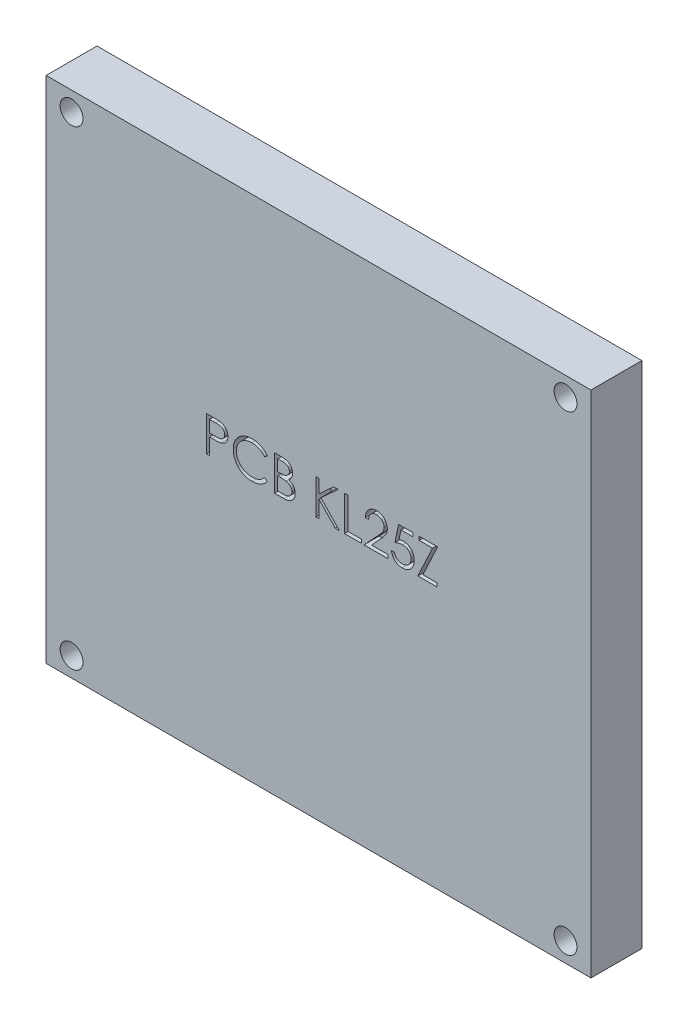
from build123d import *

# Parameters (mm, degrees)
CROQUIS1_W              = 107
CROQUIS1_H              = 100
SALIENTE_EXTRUIR1_DEPTH = 10
CORTAR_EXTRUIR1_DEPTH   = 3
CROQUIS4_R              = 2.25
CORTAR_EXTRUIR2_DEPTH   = 10


with BuildPart() as part:
    # Croquis1 → Saliente-Extruir1 (new body)
    with BuildSketch(Plane.XY):
        with Locations((9.288602269, -7.568965517)):
            Rectangle(CROQUIS1_W, CROQUIS1_H)
    extrude(amount=SALIENTE_EXTRUIR1_DEPTH)

    # Croquis2 → Cortar-Extruir1 (cut)
    with BuildSketch(Plane.XY.offset(10)):
        with BuildLine():
            Line((-12.748794183, 0.689506684), (-11.39969479, 0.689506684))
            add(Edge.make_bspline(
                [(-11.39969479, 0.689506684), (-11.306902878, 0.689404683), (-11.129109454, 0.689209245), (-10.874157601, 0.683283834), (-10.642605378, 0.675369467), (-10.43495207, 0.664398389), (-10.250558763, 0.651432947), (-10.090259832, 0.633248284), (-9.9527953, 0.614261203), (-9.870429171, 0.594957463), (-9.832865363, 0.58615382)],
                knots=[0, 0, 0, 0, 0.000278367, 0.000533364, 0.000765022, 0.000973397, 0.001157194, 0.001319416, 0.001457399, 0.001573089, 0.001573089, 0.001573089, 0.001573089], degree=3))
            add(Edge.make_bspline(
                [(-9.832865363, 0.58615382), (-9.785313549, 0.573138535), (-9.691330418, 0.547414654), (-9.555907059, 0.495892205), (-9.427062536, 0.434800949), (-9.304354795, 0.365176039), (-9.189291724, 0.284030246), (-9.080156613, 0.194652933), (-8.97791258, 0.094980552), (-8.883134582, -0.013868974), (-8.796093867, -0.130068338), (-8.721150884, -0.255352174), (-8.658398679, -0.387611628), (-8.604577511, -0.526754707), (-8.565841013, -0.673949855), (-8.536659785, -0.82817431), (-8.518137869, -0.98941154), (-8.516363906, -1.099595875), (-8.515460849, -1.155686458)],
                knots=[0, 0, 0, 0, 0.000147836, 0.000292188, 0.000433966, 0.00057532, 0.000714857, 0.000855835, 0.000998113, 0.001142656, 0.001288455, 0.00143309, 0.001579785, 0.001727203, 0.001879972, 0.002035648, 0.002197871, 0.002366082, 0.002366082, 0.002366082, 0.002366082], degree=3))
            add(Edge.make_bspline(
                [(-8.515460849, -1.155686458), (-8.51628915, -1.212248493), (-8.517909775, -1.322915935), (-8.537360688, -1.484817689), (-8.563560862, -1.639536811), (-8.603847331, -1.786730242), (-8.656611862, -1.925523858), (-8.718508742, -2.058038684), (-8.793164467, -2.182020277), (-8.87894734, -2.297918743), (-8.974374343, -2.405842868), (-9.079041725, -2.505010566), (-9.19252693, -2.594841354), (-9.314469295, -2.67553662), (-9.446057628, -2.745225094), (-9.585296195, -2.80764332), (-9.733395251, -2.860064655), (-9.835880121, -2.887640407), (-9.887986891, -2.901660851)],
                knots=[0, 0, 0, 0, 0.000169588, 0.000331811, 0.000488593, 0.000640033, 0.00078874, 0.000933598, 0.001078233, 0.001222104, 0.001365612, 0.001509879, 0.001654073, 0.001799311, 0.001947896, 0.002100268, 0.00225674, 0.002418582, 0.002418582, 0.002418582, 0.002418582], degree=3))
            add(Edge.make_bspline(
                [(-9.887986891, -2.901660851), (-9.931084544, -2.910825829), (-10.025535556, -2.930911412), (-10.181088692, -2.953334462), (-10.362198254, -2.972473484), (-10.568617045, -2.986823696), (-10.800159781, -2.999108647), (-11.056951716, -3.008873317), (-11.339496932, -3.01423878), (-11.536577675, -3.014515505), (-11.639473436, -3.014659982)],
                knots=[0, 0, 0, 0, 0.000132155, 0.000289626, 0.000471177, 0.000678438, 0.00091028, 0.001166777, 0.001449328, 0.001758012, 0.001758012, 0.001758012, 0.001758012], degree=3))
            Line((-11.639473436, -3.014659982), (-12.131433072, -3.014659982))
            Line((-12.131433072, -3.014659982), (-12.131433072, -6.189659982))
            Line((-12.131433072, -6.189659982), (-12.748794183, -6.189659982))
            Line((-12.748794183, -6.189659982), (-12.748794183, 0.689506684))
        make_face()
        with BuildLine():
            Line((-12.131433072, -0.016048871), (-12.131433072, -2.309104427))
            Line((-12.131433072, -2.309104427), (-10.92702769, -2.324262847))
            add(Edge.make_bspline(
                [(-10.92702769, -2.324262847), (-10.868220788, -2.32429324), (-10.754695276, -2.324351914), (-10.590703366, -2.316519052), (-10.438557255, -2.307476815), (-10.298724286, -2.294237518), (-10.171141424, -2.275523713), (-10.055595936, -2.256632071), (-9.952983764, -2.229301412), (-9.832894738, -2.192501665), (-9.69907854, -2.129738869), (-9.553500537, -2.038639264), (-9.430126444, -1.922517539), (-9.323365125, -1.791955218), (-9.238641548, -1.646708238), (-9.176618996, -1.491300126), (-9.140176793, -1.327324674), (-9.135290239, -1.215119296), (-9.13282196, -1.158442535)],
                knots=[0, 0, 0, 0, 0.000176394, 0.000340526, 0.000492416, 0.00063365, 0.000761689, 0.000879275, 0.000984558, 0.001080001, 0.001255748, 0.00142623, 0.001592996, 0.001761511, 0.001930735, 0.002095277, 0.002261786, 0.002431737, 0.002431737, 0.002431737, 0.002431737], degree=3))
            add(Edge.make_bspline(
                [(-9.13282196, -1.158442535), (-9.135303662, -1.103136956), (-9.140236978, -0.993196312), (-9.176904633, -0.83206901), (-9.238520963, -0.678298595), (-9.323933864, -0.534871734), (-9.4275953, -0.404779215), (-9.548077699, -0.291769981), (-9.685097454, -0.200922325), (-9.812555108, -0.14228572), (-9.925768868, -0.10648403), (-10.024105494, -0.081434349), (-10.13513657, -0.061434438), (-10.258898241, -0.045239891), (-10.394431256, -0.031376481), (-10.542900016, -0.021969757), (-10.703742093, -0.016463561), (-10.815401917, -0.016190448), (-10.8732842, -0.016048871)],
                knots=[0, 0, 0, 0, 0.000165829, 0.000329648, 0.000492909, 0.000660945, 0.000828596, 0.000990455, 0.001154419, 0.001319674, 0.001409448, 0.001510384, 0.001623903, 0.001747658, 0.001884778, 0.002032543, 0.002193868, 0.002367506, 0.002367506, 0.002367506, 0.002367506], degree=3))
            Line((-10.8732842, -0.016048871), (-12.131433072, -0.016048871))
        make_face(mode=Mode.SUBTRACT)
        with BuildLine():
            Line((-0.754349738, -0.572776302), (-1.29454071, -0.98618776))
            add(Edge.make_bspline(
                [(-1.29454071, -0.98618776), (-1.333075617, -0.940262503), (-1.409625897, -0.84903116), (-1.532781067, -0.720922317), (-1.661129892, -0.6009), (-1.794623307, -0.488392448), (-1.935664148, -0.38733402), (-2.080835789, -0.292458316), (-2.232566709, -0.207416607), (-2.442384702, -0.104301857), (-2.716859223, 0.003300407), (-3.062379793, 0.093522115), (-3.423066488, 0.15095564), (-3.669139389, 0.157176061), (-3.794301995, 0.160340018)],
                knots=[0, 0, 0, 0, 0.000179812, 0.000357199, 0.000532692, 0.000706838, 0.000880493, 0.00105288, 0.001226884, 0.001401911, 0.001754034, 0.002109015, 0.00247152, 0.002846774, 0.002846774, 0.002846774, 0.002846774], degree=3))
            add(Edge.make_bspline(
                [(-3.794301995, 0.160340018), (-3.863257385, 0.159546039), (-4.000528193, 0.15796545), (-4.2042468, 0.137113467), (-4.40416138, 0.107805839), (-4.600141893, 0.064319043), (-4.791938874, 0.009339526), (-4.980806203, -0.056357329), (-5.164009417, -0.137639282), (-5.344082883, -0.227477779), (-5.516610832, -0.328950292), (-5.679853551, -0.439632844), (-5.833215664, -0.558286866), (-5.976818489, -0.685357076), (-6.11080883, -0.820271215), (-6.234215795, -0.964467082), (-6.346612357, -1.117483675), (-6.450226414, -1.277303242), (-6.543021918, -1.443460259), (-6.620716955, -1.616569713), (-6.689518689, -1.793667182), (-6.743960891, -1.97675357), (-6.787053007, -2.164540602), (-6.816786068, -2.357532258), (-6.837400909, -2.555325359), (-6.838973638, -2.689389139), (-6.839766405, -2.75696684)],
                knots=[0, 0, 0, 0, 0.000206779, 0.000411639, 0.000613742, 0.000812686, 0.001013331, 0.001212075, 0.001412023, 0.001614163, 0.001815526, 0.002011983, 0.002205483, 0.002396827, 0.002586841, 0.002775472, 0.002965646, 0.003156, 0.003346598, 0.003535917, 0.003724788, 0.003916177, 0.004108397, 0.004302329, 0.004501702, 0.004704349, 0.004704349, 0.004704349, 0.004704349], degree=3))
            add(Edge.make_bspline(
                [(-6.839766405, -2.75696684), (-6.83728633, -2.858643518), (-6.832417031, -3.058272187), (-6.789081555, -3.35067728), (-6.723228096, -3.630798271), (-6.624530575, -3.896884128), (-6.502830156, -4.152215913), (-6.349050096, -4.392473469), (-6.17094545, -4.621287454), (-5.965996561, -4.8332502), (-5.741134654, -5.026876582), (-5.499876556, -5.197382784), (-5.242823152, -5.339515964), (-4.972812657, -5.457790354), (-4.687767283, -5.548706851), (-4.388199617, -5.612710861), (-4.074761208, -5.654461861), (-3.860584447, -5.658459026), (-3.751582811, -5.660493316)],
                knots=[0, 0, 0, 0, 0.000304858, 0.000598548, 0.000884985, 0.001166604, 0.001448267, 0.001731942, 0.002020561, 0.002316843, 0.002614885, 0.00290965, 0.003201436, 0.003494573, 0.003792663, 0.004097284, 0.004412641, 0.004739472, 0.004739472, 0.004739472, 0.004739472], degree=3))
            add(Edge.make_bspline(
                [(-3.751582811, -5.660493316), (-3.631486931, -5.657174059), (-3.395109509, -5.650640969), (-3.048462352, -5.595294635), (-2.716619675, -5.505555085), (-2.399563627, -5.37996524), (-2.09818803, -5.216702394), (-1.812021261, -5.018783114), (-1.54082177, -4.784324736), (-1.37774369, -4.605303016), (-1.29454071, -4.513965538)],
                knots=[0, 0, 0, 0, 0.000360114, 0.00070879, 0.001050104, 0.001389678, 0.001729409, 0.002076111, 0.002431703, 0.002802111, 0.002802111, 0.002802111, 0.002802111], degree=3))
            Line((-1.29454071, -4.513965538), (-0.754349738, -4.923242882))
            add(Edge.make_bspline(
                [(-0.754349738, -4.923242882), (-0.797822357, -4.97933453), (-0.884559362, -5.091249149), (-1.025008393, -5.249021283), (-1.172964129, -5.397422668), (-1.32952553, -5.535256837), (-1.49289157, -5.665281864), (-1.665995603, -5.783803678), (-1.846561999, -5.892476595), (-2.033978957, -5.991982609), (-2.22804735, -6.080266389), (-2.428534638, -6.155846354), (-2.634576638, -6.220952536), (-2.84618277, -6.274515568), (-3.063791954, -6.316323377), (-3.286618921, -6.34427181), (-3.515144593, -6.363419311), (-3.669319338, -6.365164488), (-3.747448697, -6.366048871)],
                knots=[0, 0, 0, 0, 0.000212848, 0.000424676, 0.000633202, 0.00084114, 0.001050116, 0.001259201, 0.001470009, 0.001682066, 0.001895449, 0.002109156, 0.002324456, 0.002543374, 0.00276364, 0.00298875, 0.003216831, 0.003451162, 0.003451162, 0.003451162, 0.003451162], degree=3))
            add(Edge.make_bspline(
                [(-3.747448697, -6.366048871), (-3.821436428, -6.365533931), (-3.967738004, -6.364515701), (-4.183741384, -6.348021096), (-4.394026858, -6.32551691), (-4.597993414, -6.291631843), (-4.79675411, -6.251645527), (-4.988507116, -6.198044522), (-5.175139321, -6.138000862), (-5.355900905, -6.067430466), (-5.530945625, -5.987796873), (-5.699708902, -5.897794655), (-5.862113118, -5.798180656), (-6.019754963, -5.69115063), (-6.17030569, -5.573266671), (-6.315069941, -5.446165941), (-6.454859474, -5.310276827), (-6.541345704, -5.212288299), (-6.584829339, -5.163021528)],
                knots=[0, 0, 0, 0, 0.000221903, 0.000438785, 0.000649553, 0.000856167, 0.001058865, 0.001257441, 0.001453108, 0.001646829, 0.001839227, 0.00202972, 0.002220209, 0.002410558, 0.002601036, 0.002793415, 0.002988309, 0.003185382, 0.003185382, 0.003185382, 0.003185382], degree=3))
            add(Edge.make_bspline(
                [(-6.584829339, -5.163021528), (-6.654477253, -5.077442357), (-6.792932229, -4.907317204), (-6.970072114, -4.631588448), (-7.121703797, -4.343708671), (-7.244302184, -4.042165454), (-7.340144175, -3.727635434), (-7.40654031, -3.39996006), (-7.449685666, -3.059445355), (-7.454619579, -2.827839952), (-7.457127516, -2.710113541)],
                knots=[0, 0, 0, 0, 0.000330801, 0.000657608, 0.000981212, 0.001305696, 0.001632642, 0.001966145, 0.002307654, 0.002660701, 0.002660701, 0.002660701, 0.002660701], degree=3))
            add(Edge.make_bspline(
                [(-7.457127516, -2.710113541), (-7.45407082, -2.586376096), (-7.448056962, -2.342930398), (-7.396962845, -1.985658021), (-7.314768996, -1.643367593), (-7.198025826, -1.31669809), (-7.050014951, -1.003931313), (-6.867173357, -0.707456517), (-6.6516252, -0.425377664), (-6.405060992, -0.161974861), (-6.13467567, 0.078873319), (-5.845124049, 0.290763845), (-5.536972865, 0.467101487), (-5.213616945, 0.614504659), (-4.872634968, 0.727803478), (-4.514754442, 0.807116706), (-4.140647836, 0.8564838), (-3.885406331, 0.862724596), (-3.755716926, 0.865895573)],
                knots=[0, 0, 0, 0, 0.000371061, 0.000730039, 0.001080313, 0.001425516, 0.00176885, 0.002116512, 0.002468476, 0.002832155, 0.003197218, 0.003553342, 0.003906475, 0.004260478, 0.004617812, 0.004982219, 0.005358769, 0.005747728, 0.005747728, 0.005747728, 0.005747728], degree=3))
            add(Edge.make_bspline(
                [(-3.755716926, 0.865895573), (-3.676676339, 0.864947942), (-3.520223456, 0.863072202), (-3.288783422, 0.844781201), (-3.063456658, 0.814289577), (-2.84408793, 0.772786445), (-2.629610026, 0.721276578), (-2.421662172, 0.654174635), (-2.219024157, 0.577449262), (-2.022973984, 0.489084468), (-1.834452289, 0.389893289), (-1.653517786, 0.2809752), (-1.481607689, 0.16246523), (-1.317512345, 0.035371299), (-1.163976792, -0.102995394), (-1.016641791, -0.248829002), (-0.880510791, -0.406330125), (-0.796480404, -0.51719268), (-0.754349738, -0.572776302)],
                knots=[0, 0, 0, 0, 0.000237087, 0.000469289, 0.000695946, 0.00091892, 0.001138841, 0.001357185, 0.001573958, 0.001788596, 0.002001872, 0.00221268, 0.002421766, 0.002627956, 0.002834864, 0.003041441, 0.003249506, 0.003458719, 0.003458719, 0.003458719, 0.003458719], degree=3))
        make_face()
        with BuildLine():
            Line((0.656761373, 0.689506684), (1.998970574, 0.689506684))
            add(Edge.make_bspline(
                [(1.998970574, 0.689506684), (2.064673452, 0.689161251), (2.192021982, 0.688491715), (2.377208051, 0.678107847), (2.550658987, 0.663949205), (2.712425092, 0.64148363), (2.862431616, 0.614376221), (3.001130627, 0.581549199), (3.128081072, 0.542187367), (3.27964432, 0.479594259), (3.452450285, 0.386581698), (3.63956046, 0.249138769), (3.799558554, 0.081026749), (3.937508089, -0.108607613), (4.047183861, -0.317214946), (4.126528754, -0.539823184), (4.176762149, -0.773561037), (4.181928274, -0.934028759), (4.184539151, -1.015126562)],
                knots=[0, 0, 0, 0, 0.000197079, 0.000381988, 0.000556281, 0.000719012, 0.000871726, 0.001013443, 0.001146372, 0.001269973, 0.001504891, 0.001733372, 0.001963368, 0.002198217, 0.002434919, 0.002667681, 0.002905512, 0.003148519, 0.003148519, 0.003148519, 0.003148519], degree=3))
            add(Edge.make_bspline(
                [(4.184539151, -1.015126562), (4.182390456, -1.09109724), (4.178168068, -1.240386787), (4.137791764, -1.458739613), (4.074580735, -1.666591116), (3.986713633, -1.863182733), (3.872515542, -2.044072608), (3.737176157, -2.210719961), (3.573890679, -2.356069003), (3.451553073, -2.437327494), (3.389411112, -2.478603125)],
                knots=[0, 0, 0, 0, 0.000227714, 0.00044748, 0.000663687, 0.000878325, 0.001091298, 0.001303735, 0.001520372, 0.001744014, 0.001744014, 0.001744014, 0.001744014], degree=3))
            add(Edge.make_bspline(
                [(3.389411112, -2.478603125), (3.467559286, -2.508606117), (3.617076101, -2.566009273), (3.822833966, -2.667497548), (4.000109787, -2.777882839), (4.150266558, -2.89842913), (4.278686163, -3.028364423), (4.390822361, -3.16959394), (4.486504443, -3.323959998), (4.568490201, -3.489853137), (4.632464006, -3.665579422), (4.680374266, -3.849490555), (4.707826955, -4.040927061), (4.711733616, -4.171209396), (4.713705817, -4.236979861)],
                knots=[0, 0, 0, 0, 0.000251034, 0.00048029, 0.000687129, 0.000876302, 0.001056572, 0.001234125, 0.001416131, 0.001600402, 0.001788306, 0.001976144, 0.002169664, 0.002366959, 0.002366959, 0.002366959, 0.002366959], degree=3))
            add(Edge.make_bspline(
                [(4.713705817, -4.236979861), (4.71178585, -4.304134035), (4.70800826, -4.436261753), (4.680137863, -4.630362618), (4.632948535, -4.815854329), (4.567947984, -4.993936658), (4.483113482, -5.164265089), (4.379871019, -5.327032588), (4.256770172, -5.480603754), (4.119063271, -5.626685066), (3.963275411, -5.758033491), (3.795196231, -5.875010195), (3.612709, -5.971212515), (3.418810855, -6.052025076), (3.211326705, -6.113755177), (2.991188247, -6.156941748), (2.758585339, -6.186040696), (2.598969507, -6.188433083), (2.517112935, -6.189659982)],
                knots=[0, 0, 0, 0, 0.000201425, 0.000396309, 0.000586817, 0.000774721, 0.000963919, 0.001156594, 0.001351794, 0.001553558, 0.001757884, 0.001962001, 0.002166681, 0.002375507, 0.002591314, 0.002814815, 0.003047961, 0.003293391, 0.003293391, 0.003293391, 0.003293391], degree=3))
            Line((2.517112935, -6.189659982), (0.656761373, -6.189659982))
            Line((0.656761373, -6.189659982), (0.656761373, 0.689506684))
        make_face()
        with BuildLine():
            Line((1.274122484, -0.016048871), (1.274122484, -2.220909982))
            Line((1.274122484, -2.220909982), (1.688911981, -2.220909982))
            add(Edge.make_bspline(
                [(1.688911981, -2.220909982), (1.749544553, -2.220123943), (1.86669904, -2.218605155), (2.036358742, -2.21425454), (2.193842557, -2.202072434), (2.338878648, -2.189893828), (2.471238618, -2.170092466), (2.590629232, -2.146522234), (2.698924212, -2.121594286), (2.823809676, -2.079199973), (2.96546734, -2.016545161), (3.116480977, -1.919309445), (3.249611464, -1.803495032), (3.362031175, -1.669860416), (3.454038006, -1.52271271), (3.517942939, -1.364399734), (3.561276351, -1.19886707), (3.565190658, -1.085226671), (3.56717804, -1.027528906)],
                knots=[0, 0, 0, 0, 0.000181922, 0.00035151, 0.000508993, 0.000655714, 0.000788041, 0.000910198, 0.001020828, 0.001121056, 0.001305471, 0.001483984, 0.001657825, 0.001832857, 0.002006101, 0.002176025, 0.002343472, 0.002516173, 0.002516173, 0.002516173, 0.002516173], degree=3))
            add(Edge.make_bspline(
                [(3.56717804, -1.027528906), (3.566143845, -0.989348015), (3.564115159, -0.914452027), (3.547500394, -0.805271094), (3.519261269, -0.702587242), (3.482989795, -0.604993271), (3.432302741, -0.515540813), (3.372624077, -0.431136984), (3.300519226, -0.354656142), (3.218446222, -0.283172759), (3.124086417, -0.219796907), (3.017496104, -0.164290359), (2.897233182, -0.119593904), (2.765324463, -0.080449181), (2.619739505, -0.052955522), (2.462158329, -0.030051066), (2.291290208, -0.018390403), (2.173076441, -0.016846791), (2.111969706, -0.016048871)],
                knots=[0, 0, 0, 0, 0.00011451, 0.000224624, 0.000330257, 0.000433647, 0.00053604, 0.000637763, 0.000743073, 0.000850542, 0.000963675, 0.001083247, 0.001210184, 0.001347988, 0.001495547, 0.001654184, 0.00182551, 0.002008835, 0.002008835, 0.002008835, 0.002008835], degree=3))
            Line((2.111969706, -0.016048871), (1.274122484, -0.016048871))
        make_face(mode=Mode.SUBTRACT)
        with BuildLine():
            Line((1.274122484, -2.926465538), (1.274122484, -5.484104427))
            Line((1.274122484, -5.484104427), (2.153310852, -5.484104427))
            add(Edge.make_bspline(
                [(2.153310852, -5.484104427), (2.216243289, -5.483350181), (2.337537263, -5.48189647), (2.51266361, -5.477150721), (2.674978734, -5.466355783), (2.823741963, -5.449362572), (2.96055965, -5.430929453), (3.083790493, -5.406142281), (3.194433424, -5.377743193), (3.322728522, -5.333845909), (3.467197917, -5.265650822), (3.622884969, -5.162828455), (3.761306024, -5.040333478), (3.878851837, -4.898561883), (3.975185699, -4.744406978), (4.045265647, -4.580986772), (4.088488153, -4.411001527), (4.093720583, -4.295103857), (4.096344706, -4.236979861)],
                knots=[0, 0, 0, 0, 0.000188811, 0.000363909, 0.000525516, 0.00067663, 0.000813048, 0.000939528, 0.001053506, 0.001155481, 0.001345959, 0.001530945, 0.001713477, 0.001898386, 0.002081561, 0.002256897, 0.002430026, 0.002604205, 0.002604205, 0.002604205, 0.002604205], degree=3))
            add(Edge.make_bspline(
                [(4.096344706, -4.236979861), (4.09580203, -4.20063164), (4.09472543, -4.1285215), (4.078489388, -4.022551241), (4.054876413, -3.91990253), (4.02434975, -3.820296638), (3.979891726, -3.725534395), (3.92799029, -3.633741626), (3.867136392, -3.544796989), (3.772313633, -3.432347667), (3.634392268, -3.302789348), (3.438420975, -3.175942424), (3.215590423, -3.073643698), (3.053974243, -3.030207704), (2.970487501, -3.007769791)],
                knots=[0, 0, 0, 0, 0.000108943, 0.00021613, 0.000320761, 0.000424919, 0.000527904, 0.000634048, 0.000741075, 0.000850644, 0.001074896, 0.00130575, 0.0015481, 0.001807069, 0.001807069, 0.001807069, 0.001807069], degree=3))
            add(Edge.make_bspline(
                [(2.970487501, -3.007769791), (2.937017219, -3.000978906), (2.864446743, -2.986254866), (2.746110177, -2.970712464), (2.611011463, -2.956865566), (2.458838641, -2.94662316), (2.289399182, -2.936036037), (2.102331215, -2.931918716), (1.898398683, -2.927006479), (1.756899389, -2.926650464), (1.683399828, -2.926465538)],
                knots=[0, 0, 0, 0, 0.00010243, 0.000222089, 0.000357838, 0.000509823, 0.000679596, 0.00086709, 0.001071082, 0.001291572, 0.001291572, 0.001291572, 0.001291572], degree=3))
            Line((1.683399828, -2.926465538), (1.274122484, -2.926465538))
        make_face(mode=Mode.SUBTRACT)
        Polygon((8.770650262, 0.689506684), (9.388011373, 0.689506684), (9.388011373, -1.930143923), (12.255708856, 0.689506684), (13.136275262, 0.689506684), (9.755947571, -2.397298871), (13.400858595, -6.189659982), (12.578169793, -6.189659982), (9.388011373, -2.869965972), (9.388011373, -6.189659982), (8.770650262, -6.189659982), align=None)
        Polygon((14.415094706, 0.689506684), (15.032455817, 0.689506684), (15.032455817, -5.484104427), (17.678289151, -5.484104427), (17.678289151, -6.189659982), (14.415094706, -6.189659982), align=None)
        with BuildLine():
            Line((19.089400262, -1.427159982), (18.472039151, -1.427159982))
            add(Edge.make_bspline(
                [(18.472039151, -1.427159982), (18.476062781, -1.345256845), (18.483965084, -1.184401262), (18.520971639, -0.949872965), (18.573923291, -0.725700974), (18.648791137, -0.513685226), (18.7417705, -0.311951094), (18.853272018, -0.121299873), (18.985339931, 0.057541142), (19.135122453, 0.222914035), (19.297802242, 0.374624368), (19.47333094, 0.505633661), (19.657781106, 0.616324703), (19.850593139, 0.708861763), (20.053942414, 0.778321388), (20.265983602, 0.829859397), (20.48764831, 0.860867429), (20.638675543, 0.864200455), (20.715485331, 0.865895573)],
                knots=[0, 0, 0, 0, 0.000245848, 0.000482838, 0.000711119, 0.000936005, 0.001156121, 0.001376628, 0.001597398, 0.00182182, 0.002045134, 0.002263691, 0.002477572, 0.002689615, 0.002904032, 0.003120949, 0.00334351, 0.003573844, 0.003573844, 0.003573844, 0.003573844], degree=3))
            add(Edge.make_bspline(
                [(20.715485331, 0.865895573), (20.790916522, 0.864129678), (20.939136118, 0.860659758), (21.155460386, 0.830861116), (21.361397664, 0.784189721), (21.556545405, 0.718709064), (21.739346611, 0.630686338), (21.911174523, 0.524948557), (22.074074783, 0.402656959), (22.22071264, 0.258678333), (22.355363639, 0.104973409), (22.471527714, -0.059120078), (22.571006682, -0.228601686), (22.653925562, -0.404763782), (22.714965664, -0.589265054), (22.76130807, -0.779419377), (22.787502785, -0.977195048), (22.791523016, -1.111056861), (22.793566928, -1.179113107)],
                knots=[0, 0, 0, 0, 0.000226204, 0.000444483, 0.000653745, 0.000858999, 0.001060555, 0.001260974, 0.00146355, 0.001670164, 0.001876285, 0.002075887, 0.00227229, 0.002465264, 0.00265875, 0.002854281, 0.003051706, 0.003255884, 0.003255884, 0.003255884, 0.003255884], degree=3))
            add(Edge.make_bspline(
                [(22.793566928, -1.179113107), (22.790238861, -1.274925816), (22.783641128, -1.464869855), (22.727203704, -1.743996686), (22.639058955, -2.014433275), (22.532928435, -2.232084806), (22.425864144, -2.407471113), (22.329383816, -2.551872104), (22.216438098, -2.707352018), (22.085383098, -2.873390213), (21.938929822, -3.051287242), (21.775751737, -3.240935638), (21.594685226, -3.440375985), (21.467600482, -3.576594495), (21.401748352, -3.647179514)],
                knots=[0, 0, 0, 0, 0.000287191, 0.000569343, 0.000850854, 0.001138679, 0.001293241, 0.001467141, 0.001659539, 0.001869599, 0.002101621, 0.002350787, 0.002620073, 0.002909674, 0.002909674, 0.002909674, 0.002909674], degree=3))
            Line((21.401748352, -3.647179514), (19.680578647, -5.484104427))
            Line((19.680578647, -5.484104427), (22.881761373, -5.484104427))
            Line((22.881761373, -5.484104427), (22.881761373, -6.189659982))
            Line((22.881761373, -6.189659982), (18.207455817, -6.189659982))
            Line((18.207455817, -6.189659982), (20.875337762, -3.342633073))
            add(Edge.make_bspline(
                [(20.875337762, -3.342633073), (20.940292596, -3.274827473), (21.06505754, -3.144586792), (21.241523057, -2.954440807), (21.400017069, -2.778040221), (21.54156554, -2.615718327), (21.663097822, -2.465100805), (21.770947888, -2.331065739), (21.85736121, -2.207723361), (21.951144684, -2.064753416), (22.041977164, -1.890194921), (22.120030855, -1.676874539), (22.167624563, -1.457277284), (22.173333948, -1.308879828), (22.176205817, -1.234234635)],
                knots=[0, 0, 0, 0, 0.00028169, 0.000541069, 0.000778192, 0.00099313, 0.001187047, 0.001358794, 0.001509057, 0.001638637, 0.001871619, 0.002097432, 0.002318512, 0.002542268, 0.002542268, 0.002542268, 0.002542268], degree=3))
            add(Edge.make_bspline(
                [(22.176205817, -1.234234635), (22.174956281, -1.187296315), (22.172493685, -1.0947899), (22.150760044, -0.959160724), (22.117915942, -0.828329167), (22.070852107, -0.701892798), (22.008729812, -0.581122832), (21.9331113, -0.46587226), (21.845863687, -0.354451449), (21.74493399, -0.249979907), (21.634058491, -0.154298157), (21.516927412, -0.069538794), (21.393003934, 0.00129522), (21.262810551, 0.059362261), (21.126710229, 0.104912921), (20.984439736, 0.136475676), (20.836392175, 0.156292558), (20.735300864, 0.158973806), (20.683790453, 0.160340018)],
                knots=[0, 0, 0, 0, 0.000140729, 0.000277349, 0.00041104, 0.000544909, 0.000681112, 0.000817565, 0.000957888, 0.001105055, 0.001252582, 0.001396757, 0.001538112, 0.001679989, 0.001823795, 0.001967884, 0.002116591, 0.002271085, 0.002271085, 0.002271085, 0.002271085], degree=3))
            add(Edge.make_bspline(
                [(20.683790453, 0.160340018), (20.629993733, 0.158934639), (20.524345857, 0.156174707), (20.369232377, 0.136868494), (20.221259974, 0.103561849), (20.080056424, 0.058008647), (19.945382809, 0.000108571), (19.817894075, -0.07200818), (19.69787642, -0.158063593), (19.58510423, -0.255630925), (19.481201337, -0.364258079), (19.389911109, -0.485350995), (19.310144195, -0.616698688), (19.24054819, -0.757946752), (19.184029566, -0.91037686), (19.140841862, -1.073447908), (19.106668429, -1.246451838), (19.09525192, -1.365923475), (19.089400262, -1.427159982)],
                knots=[0, 0, 0, 0, 0.000161378, 0.000316919, 0.000468033, 0.000615766, 0.000761428, 0.000907057, 0.001054275, 0.001203746, 0.001353858, 0.001504342, 0.001657725, 0.001814265, 0.001976036, 0.002144518, 0.002319919, 0.00250436, 0.00250436, 0.00250436, 0.00250436], degree=3))
        make_face()
        with BuildLine():
            Line((27.820650262, 0.689506684), (27.820650262, -0.016048871))
            Line((27.820650262, -0.016048871), (25.480741408, -0.016048871))
            Line((25.480741408, -0.016048871), (25.110049133, -1.825413021))
            add(Edge.make_bspline(
                [(25.110049133, -1.825413021), (25.182881572, -1.805305665), (25.323982903, -1.766350844), (25.532244487, -1.723099026), (25.729956068, -1.697026111), (25.858253254, -1.693466024), (25.920335592, -1.691743316)],
                knots=[0, 0, 0, 0, 0.000226623, 0.000439047, 0.000637661, 0.00082388, 0.00082388, 0.00082388, 0.00082388], degree=3))
            add(Edge.make_bspline(
                [(25.920335592, -1.691743316), (25.997153751, -1.693405982), (26.148197447, -1.6966752), (26.36919352, -1.72806749), (26.580153766, -1.777479393), (26.780636996, -1.846507943), (26.971014102, -1.934776954), (27.149533512, -2.045040051), (27.318874838, -2.173844253), (27.476000103, -2.32193308), (27.618544904, -2.484913544), (27.743875439, -2.660151216), (27.85033072, -2.845943086), (27.935948347, -3.044064282), (28.004316128, -3.252324475), (28.049820822, -3.472914944), (28.080121997, -3.703756428), (28.083507306, -3.861593148), (28.085233595, -3.942079687)],
                knots=[0, 0, 0, 0, 0.000230334, 0.000452895, 0.000668152, 0.000879513, 0.001087889, 0.001296342, 0.001507739, 0.001725142, 0.001942929, 0.002156307, 0.002370475, 0.002583996, 0.002802761, 0.003026823, 0.003258767, 0.003500117, 0.003500117, 0.003500117, 0.003500117], degree=3))
            add(Edge.make_bspline(
                [(28.085233595, -3.942079687), (28.083926405, -3.998139432), (28.081329692, -4.109501323), (28.068124468, -4.274884746), (28.042699626, -4.436766934), (28.008563778, -4.595169361), (27.964257192, -4.749792139), (27.910621206, -4.901077845), (27.844982109, -5.048084863), (27.772984013, -5.192204181), (27.691915043, -5.330177676), (27.601938477, -5.459209196), (27.506877255, -5.581234373), (27.404591151, -5.694944508), (27.294129433, -5.799592392), (27.176829879, -5.895799073), (27.053628488, -5.985191545), (26.922619196, -6.064141176), (26.786721292, -6.136790987), (26.64397226, -6.196391177), (26.497621526, -6.249676275), (26.345562705, -6.292149287), (26.188140224, -6.32542982), (26.025094588, -6.348033976), (25.857280914, -6.364497665), (25.743528954, -6.365528276), (25.686069099, -6.366048871)],
                knots=[0, 0, 0, 0, 0.000168211, 0.000334149, 0.000497276, 0.000659452, 0.000819968, 0.0009795, 0.001140547, 0.00130263, 0.00146263, 0.001620119, 0.001774219, 0.001926429, 0.002078488, 0.002230229, 0.002381292, 0.002534676, 0.002688776, 0.002843123, 0.002998297, 0.003155786, 0.003316326, 0.003480613, 0.003649416, 0.00382172, 0.00382172, 0.00382172, 0.00382172], degree=3))
            add(Edge.make_bspline(
                [(25.686069099, -6.366048871), (25.617524727, -6.364691046), (25.482671773, -6.362019684), (25.285100991, -6.33407359), (25.095010737, -6.294048797), (24.913931216, -6.233833938), (24.740239602, -6.158384625), (24.576274236, -6.063027245), (24.417845502, -5.954967125), (24.271393868, -5.827446336), (24.135469174, -5.688063252), (24.013793405, -5.53680484), (23.905429672, -5.376167568), (23.812113291, -5.205371315), (23.732515394, -5.024864869), (23.669983792, -4.833971923), (23.619513597, -4.633689892), (23.598161803, -4.495804837), (23.587316928, -4.425771094)],
                knots=[0, 0, 0, 0, 0.000205494, 0.000404285, 0.00059755, 0.000787549, 0.000975741, 0.001164613, 0.001355743, 0.001550203, 0.001746083, 0.001939132, 0.002131762, 0.002326646, 0.002522254, 0.00272271, 0.002928592, 0.003141096, 0.003141096, 0.003141096, 0.003141096], degree=3))
            Line((23.587316928, -4.425771094), (24.20467804, -4.425771094))
            add(Edge.make_bspline(
                [(24.20467804, -4.425771094), (24.219868335, -4.491371716), (24.249064927, -4.617459755), (24.313150749, -4.794610761), (24.391506178, -4.952476283), (24.484678297, -5.093144594), (24.595826035, -5.215807993), (24.722657091, -5.325122004), (24.864854819, -5.423740026), (25.022865797, -5.505941679), (25.189563885, -5.576047764), (25.364033723, -5.622731155), (25.541524766, -5.655556363), (25.661572848, -5.658842169), (25.721898092, -5.660493316)],
                knots=[0, 0, 0, 0, 0.000201872, 0.000388009, 0.000563648, 0.000729523, 0.000892487, 0.001058551, 0.001230944, 0.001410332, 0.001592024, 0.001772231, 0.001951207, 0.002131987, 0.002131987, 0.002131987, 0.002131987], degree=3))
            add(Edge.make_bspline(
                [(25.721898092, -5.660493316), (25.780780701, -5.658880096), (25.89672104, -5.655703654), (26.067346754, -5.631255072), (26.232078962, -5.593601322), (26.389292208, -5.537251404), (26.541737567, -5.46876494), (26.685558871, -5.380878523), (26.824916787, -5.279735082), (26.955479702, -5.163857229), (27.075058191, -5.036160842), (27.180714567, -4.899604679), (27.268722525, -4.753929782), (27.342888017, -4.601658144), (27.399205394, -4.441120885), (27.439381656, -4.273070361), (27.462973382, -4.097091489), (27.466218737, -3.977061215), (27.467872484, -3.915896962)],
                knots=[0, 0, 0, 0, 0.000176583, 0.000347693, 0.000516157, 0.000682644, 0.000847899, 0.00101664, 0.001187255, 0.001363951, 0.001539444, 0.001711434, 0.001880887, 0.002049149, 0.002218693, 0.002390157, 0.002566729, 0.002750195, 0.002750195, 0.002750195, 0.002750195], degree=3))
            add(Edge.make_bspline(
                [(27.467872484, -3.915896962), (27.466578258, -3.86071474), (27.464044996, -3.752703394), (27.44334741, -3.594680668), (27.407345837, -3.445160914), (27.357375807, -3.303422104), (27.293931203, -3.169330553), (27.216400415, -3.042747871), (27.123328439, -2.925342444), (27.01701212, -2.817059342), (26.900541851, -2.717124951), (26.771913733, -2.631933181), (26.63381952, -2.560264219), (26.48792301, -2.498414618), (26.330753905, -2.453993391), (26.165424667, -2.420643416), (25.990149971, -2.401351554), (25.870313535, -2.398674795), (25.808714498, -2.397298871)],
                knots=[0, 0, 0, 0, 0.000165508, 0.000323958, 0.000477039, 0.000626096, 0.000774035, 0.000921279, 0.001070426, 0.001222448, 0.001375955, 0.001529981, 0.001684082, 0.001842238, 0.002004461, 0.0021731, 0.002347801, 0.002532587, 0.002532587, 0.002532587, 0.002532587], degree=3))
            add(Edge.make_bspline(
                [(25.808714498, -2.397298871), (25.755393234, -2.398440009), (25.645298353, -2.40079617), (25.476419082, -2.418144439), (25.298952851, -2.446131434), (25.113579955, -2.484627737), (24.919743695, -2.535005008), (24.717853124, -2.595373627), (24.507483752, -2.667549842), (24.365738082, -2.722056847), (24.292872484, -2.750076649)],
                knots=[0, 0, 0, 0, 0.000159947, 0.000330251, 0.00050878, 0.000698774, 0.000897976, 0.001109427, 0.001330807, 0.001564997, 0.001564997, 0.001564997, 0.001564997], degree=3))
            Line((24.292872484, -2.750076649), (24.99842804, 0.689506684))
            Line((24.99842804, 0.689506684), (27.820650262, 0.689506684))
        make_face()
        Polygon((29.055372484, -0.016048871), (29.055372484, 0.689506684), (32.671344706, 0.689506684), (29.785732727, -5.484104427), (32.583150262, -5.484104427), (32.583150262, -6.189659982), (28.790789151, -6.189659982), (31.67640113, -0.016048871), align=None)
    extrude(amount=-CORTAR_EXTRUIR1_DEPTH, mode=Mode.SUBTRACT)

    # Croquis4 → Cortar-Extruir2 (cut)
    with BuildSketch(Plane.XY.offset(10)):
        with Locations((57.788602269, 38.681034483)):
            Circle(CROQUIS4_R)
        with Locations((57.788602269, -53.738965517)):
            Circle(CROQUIS4_R)
        with Locations((-39.211397731, -53.738965517)):
            Circle(CROQUIS4_R)
        with Locations((-39.211397731, 38.681034483)):
            Circle(CROQUIS4_R)
    extrude(amount=-CORTAR_EXTRUIR2_DEPTH, mode=Mode.SUBTRACT)


solid = part.part
